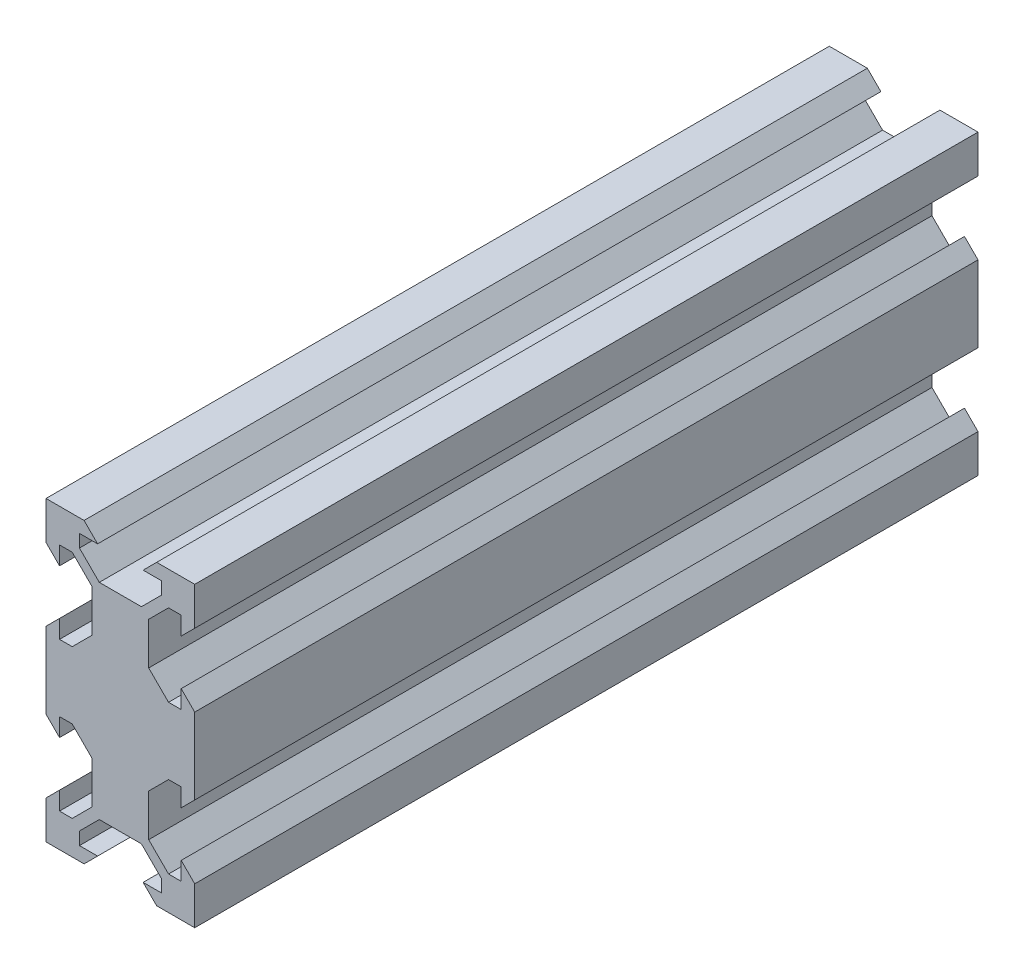
from build123d import *

# Parameters (mm, degrees)
SKETCH1_W           = 20
SKETCH1_H           = 40
BOSS_EXTRUDE1_DEPTH = 105.33
CUT_EXTRUDE1_DEPTH  = 106.33


with BuildPart() as part:
    # Sketch1 → Boss-Extrude1 (new body)
    with BuildSketch(Plane.XY):
        with Locations((10, 20)):
            Rectangle(SKETCH1_W, SKETCH1_H)
    extrude(amount=BOSS_EXTRUDE1_DEPTH)

    # Sketch2 → Cut-Extrude1 (cut, through all)
    with BuildSketch(Plane.XY.offset(105.33)):
        Polygon((5.12, 40), (6.94, 38.18), (4.5, 38.18), (4.5, 36.475807358), (7.165807358, 33.81), (12.834192642, 33.81), (15.5, 36.475807358), (15.5, 38.18), (13.06, 38.18), (14.88, 40), align=None)
        Polygon((18.18, 35.5), (18.18, 33.06), (20, 34.88), (20, 25.12), (18.18, 26.94), (18.18, 24.5), (16.475807358, 24.5), (13.81, 27.165807358), (13.81, 32.834192642), (16.475807358, 35.5), align=None)
        Polygon((20, 14.88), (18.18, 13.06), (18.18, 15.5), (16.475807358, 15.5), (13.81, 12.834192642), (13.81, 7.165807358), (16.475807358, 4.5), (18.18, 4.5), (18.18, 6.94), (20, 5.12), align=None)
        Polygon((15.5, 1.82), (13.06, 1.82), (14.88, 0), (5.12, 0), (6.94, 1.82), (4.5, 1.82), (4.5, 3.524192642), (7.165807358, 6.19), (12.834192642, 6.19), (15.5, 3.524192642), align=None)
        Polygon((1.82, 4.5), (1.82, 6.94), (0, 5.12), (0, 14.88), (1.82, 13.06), (1.82, 15.5), (3.524192642, 15.5), (6.19, 12.834192642), (6.19, 7.165807358), (3.524192642, 4.5), align=None)
        Polygon((0, 25.12), (1.82, 26.94), (1.82, 24.5), (3.524192642, 24.5), (6.19, 27.165807358), (6.19, 32.834192642), (3.524192642, 35.5), (1.82, 35.5), (1.82, 33.06), (0, 34.88), align=None)
    extrude(amount=-CUT_EXTRUDE1_DEPTH, mode=Mode.SUBTRACT)


solid = part.part
